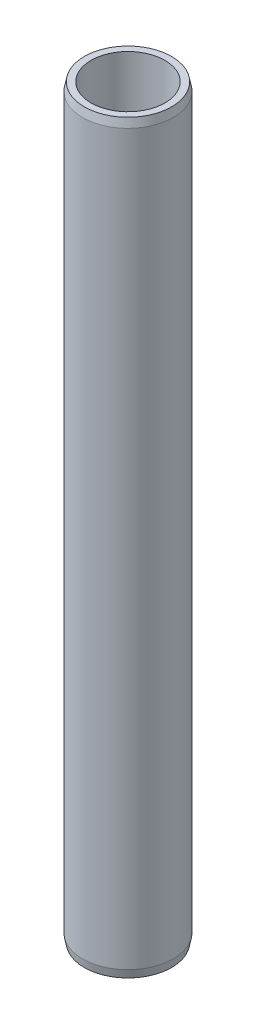
from build123d import *

# Parameters (mm, degrees)
ESQUISSE1_R      = 13.5
ESQUISSE1_R_2    = 11
EXTRUSION1_DEPTH = 111
CHANFREIN1_SIZE  = 2.5
CHANFREIN1_SIZE2 = 0.5
CHANFREIN2_SIZE  = 2.5
CHANFREIN2_SIZE2 = 0.5


with BuildPart() as part:
    # Esquisse1 → Extrusion1 (new body, symmetric)
    with BuildSketch(Plane(origin=(0, 0, 0), x_dir=(1, 0, 0), z_dir=(0, 1, 0))):
        with Locations(Location((0, 0, 0), (0, 0, 270))):  # turned: the seam where the file's is
            Circle(ESQUISSE1_R)
        with Locations(Location((0, 0, 0), (0, 0, 270))):  # turned: the seam where the file's is
            Circle(ESQUISSE1_R_2, mode=Mode.SUBTRACT)
    extrude(amount=EXTRUSION1_DEPTH, both=True)

    # Chanfrein1
    chanfrein1_edges = [part.edges().sort_by_distance(p)[0] for p in [
        (0, -111, -13.5),
    ]]
    chanfrein1_side = [part.faces().sort_by_distance(p)[0] for p in [
        (0, 0, -13.5),
    ]]
    chamfer(chanfrein1_edges, length=CHANFREIN1_SIZE, length2=CHANFREIN1_SIZE2, reference=chanfrein1_side[0])

    # Chanfrein2
    chanfrein2_edges = [part.edges().sort_by_distance(p)[0] for p in [
        (0, 111, -13.5),
    ]]
    chanfrein2_side = [part.faces().sort_by_distance(p)[0] for p in [
        (0, 1.25, -13.5),
    ]]
    chamfer(chanfrein2_edges, length=CHANFREIN2_SIZE, length2=CHANFREIN2_SIZE2, reference=chanfrein2_side[0])


solid = part.part
